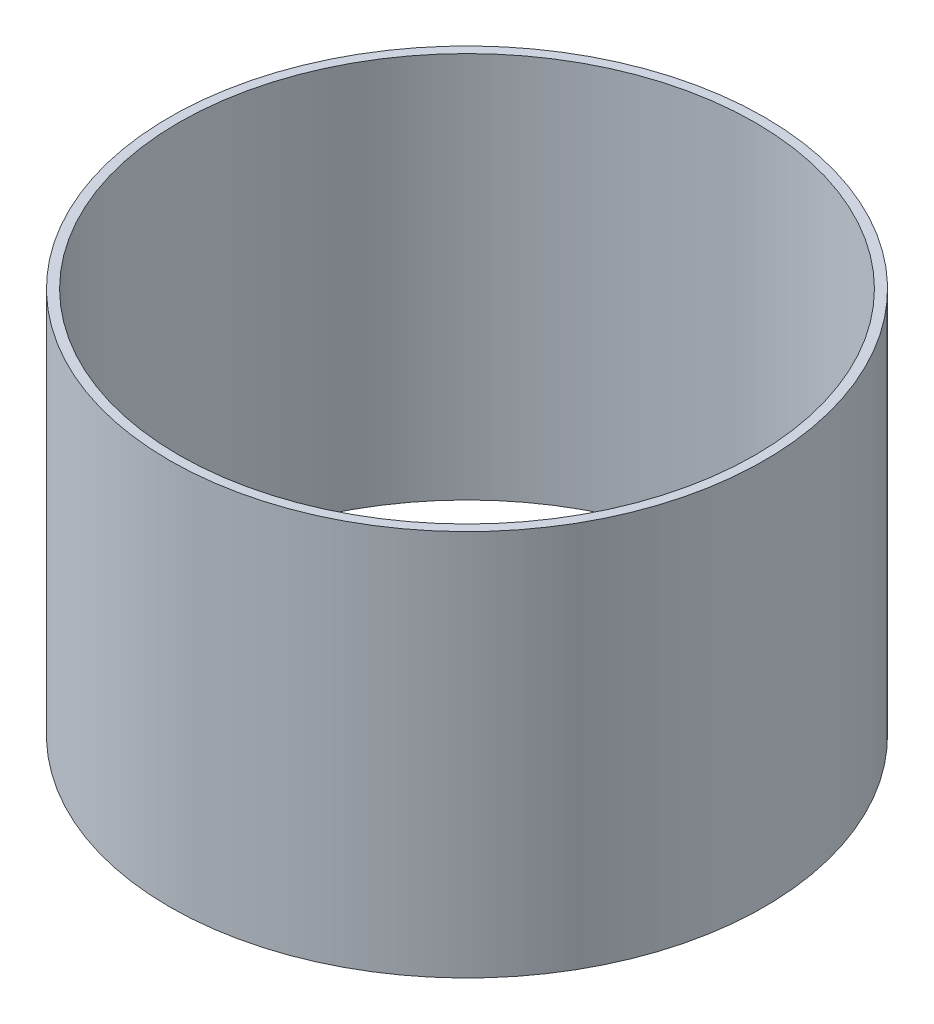
from build123d import *

# Parameters (mm, degrees)
SKETCH1_R           = 152.4
SKETCH1_R_2         = 147.6375
BOSS_EXTRUDE1_DEPTH = 198.12


with BuildPart() as part:
    # Sketch1 → Boss-Extrude1 (new body)
    with BuildSketch(Plane(origin=(0, 0, 0), x_dir=(1, 0, 0), z_dir=(0, 1, 0))):
        Circle(SKETCH1_R)
        Circle(SKETCH1_R_2, mode=Mode.SUBTRACT)
    extrude(amount=BOSS_EXTRUDE1_DEPTH)


solid = part.part
